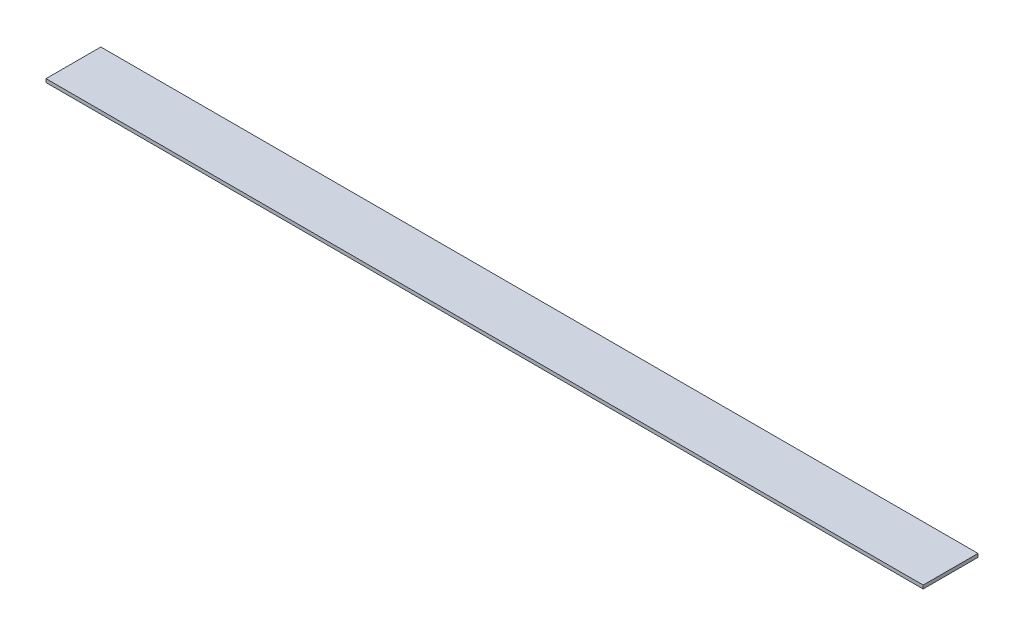
from build123d import *

# Parameters (mm, degrees)
SKETCH1_W           = 406.4
SKETCH1_H           = 25.4
BOSS_EXTRUDE1_DEPTH = 1.5875


with BuildPart() as part:
    # Sketch1 → Boss-Extrude1 (new body)
    with BuildSketch(Plane(origin=(0, 0, 0), x_dir=(1, 0, 0), z_dir=(0, 1, 0))):
        with Locations((203.2, 12.7)):
            Rectangle(SKETCH1_W, SKETCH1_H)
    extrude(amount=BOSS_EXTRUDE1_DEPTH)


solid = part.part
